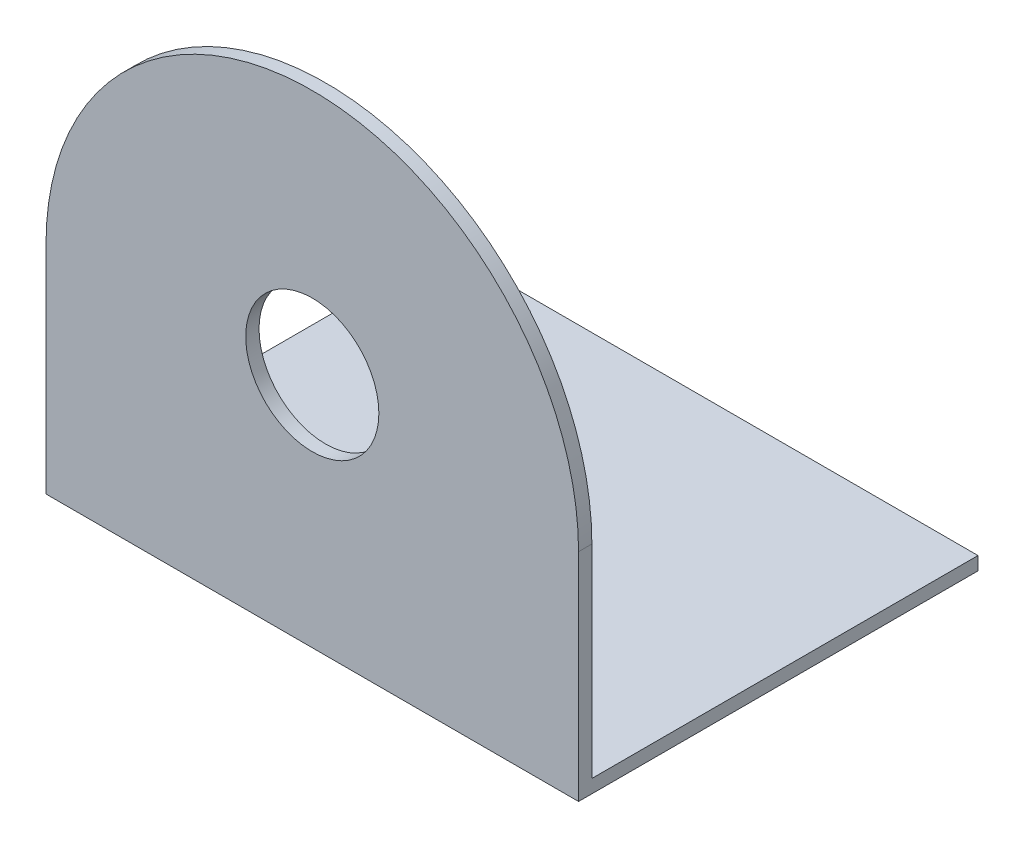
from build123d import *

# Parameters (mm, degrees)
BOSS_EXTRUDE1_DEPTH = 1
SKETCH4_W           = 40
SKETCH4_H           = 1
BOSS_EXTRUDE2_DEPTH = 30
SKETCH5_R           = 5
CUT_EXTRUDE1_DEPTH  = 47


with BuildPart() as part:
    # Sketch3 → Boss-Extrude1 (new body)
    with BuildSketch(Plane.XY):
        with BuildLine():
            Line((-20, 0), (-20, -15.25))
            Line((-20, -15.25), (20, -15.25))
            Line((20, -15.25), (20, 0))
            ThreePointArc((20, 0), (0, 20), (-20, 0))
        make_face()
    extrude(amount=BOSS_EXTRUDE1_DEPTH)

    # Sketch4 → Boss-Extrude2 (add)
    with BuildSketch(Plane.XY.offset(1)):
        with Locations((0, -15.75)):
            Rectangle(SKETCH4_W, SKETCH4_H)
    extrude(amount=-BOSS_EXTRUDE2_DEPTH)

    # Sketch5 → Cut-Extrude1 (cut)
    with BuildSketch(Plane.XY.offset(1)):
        with Locations((0, 1.5)):
            Circle(SKETCH5_R)
    extrude(amount=-CUT_EXTRUDE1_DEPTH, mode=Mode.SUBTRACT)


solid = part.part
